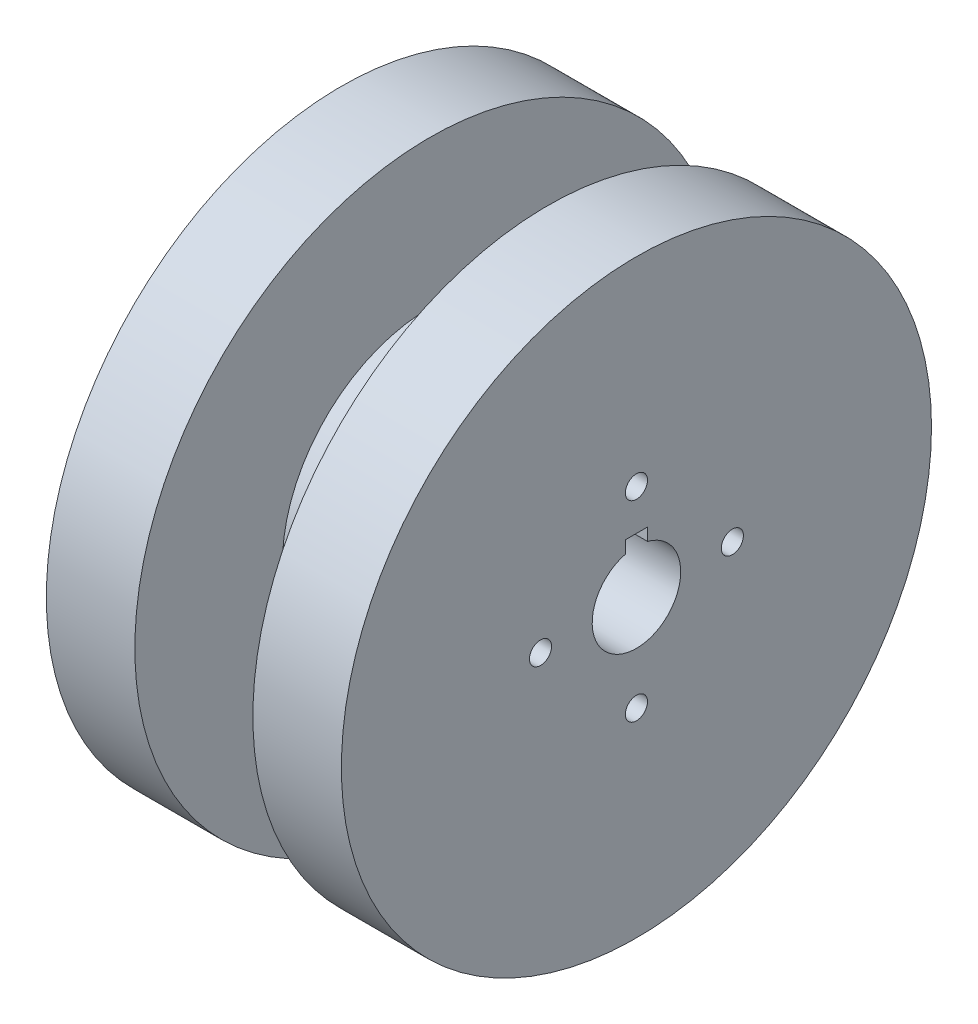
from build123d import *

# Parameters (mm, degrees)
ESBO_O6_R             = 6
CORTE_EXTRUS_O3_DEPTH = 41
ESBO_O7_R             = 1.5
CORTE_EXTRUS_O4_DEPTH = 41
CORTE_EXTRUS_O6_DEPTH = 4
ESBO_O10_W            = 50.246941072
ESBO_O10_H            = 50.246941072
CORTE_EXTRUS_O7_DEPTH = 3


with BuildPart() as part:
    # Esboço5 → Revolução1 (revolve)
    with BuildSketch(Plane.XY):
        Polygon((0, 0), (0, 40), (12, 40), (12, 20), (28, 20), (28, 40), (40, 40), (40, 0), align=None)
    revolve(axis=Axis((40, 0, 0), (-1, 0, 0)))

    # Esboço6 → Corte-extrusão3 (cut, through all)
    with BuildSketch(Plane.ZY):
        Circle(ESBO_O6_R)
        with BuildLine():
            Line((0, 7.5), (-1.5, 7.5))
            Line((-1.5, 7.5), (-1.5, 5.809475019))
            ThreePointArc((-1.5, 5.809475019), (0, 6), (1.5, 5.809475019))
            Line((1.5, 5.809475019), (1.5, 7.5))
            Line((1.5, 7.5), (0, 7.5))
        make_face()
    extrude(amount=-CORTE_EXTRUS_O3_DEPTH, mode=Mode.SUBTRACT)

    # Esboço7 → Corte-extrusão4 (cut, through all)
    with BuildSketch(Plane.ZY):
        with Locations((0, 13.001726509)):
            Circle(ESBO_O7_R)
        with Locations((13.001726509, 0)):
            Circle(ESBO_O7_R)
        with Locations((0, -13.001726509)):
            Circle(ESBO_O7_R)
        with Locations((-13.001726509, 0)):
            Circle(ESBO_O7_R)
    extrude(amount=-CORTE_EXTRUS_O4_DEPTH, mode=Mode.SUBTRACT)

    # Esboço9 → Corte-extrusão6 (cut)
    with BuildSketch(Plane.ZY):
        Polygon((0, -32.845160811), (32.845160811, 0), (0, 32.845160811), (-32.845160811, 0), align=None)
    extrude(amount=-CORTE_EXTRUS_O6_DEPTH, mode=Mode.SUBTRACT)

    # Esboço10 → Corte-extrusão7 (cut)
    with BuildSketch(Plane.ZY):
        Rectangle(ESBO_O10_W, ESBO_O10_H)
    extrude(amount=-CORTE_EXTRUS_O7_DEPTH, mode=Mode.SUBTRACT)


solid = part.part
